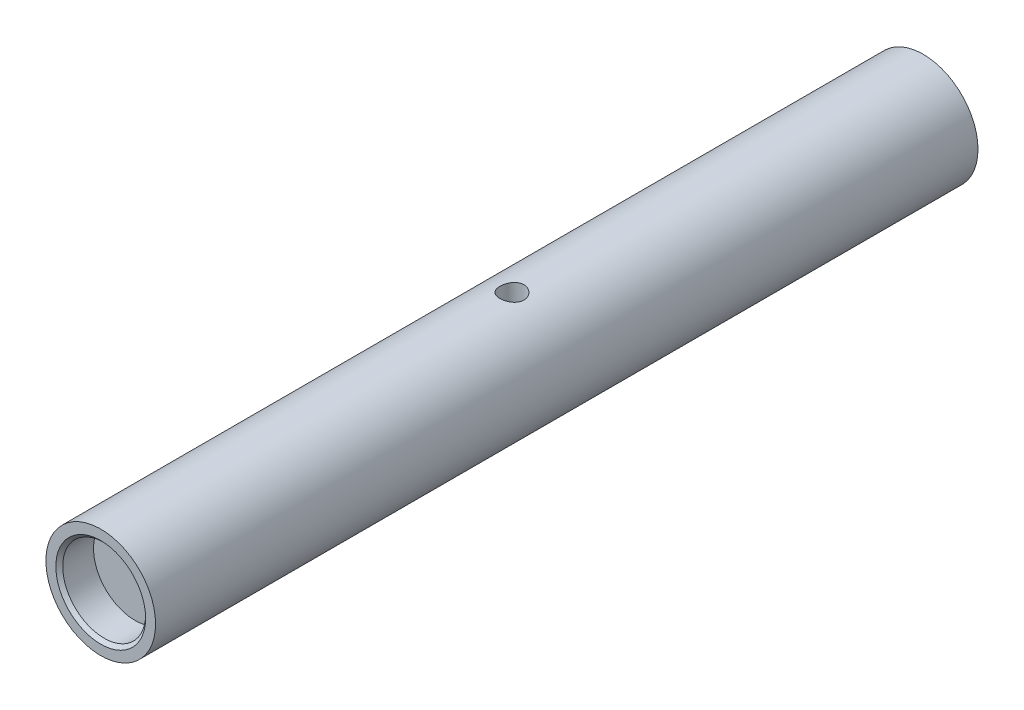
from build123d import *

# Parameters (mm, degrees)
SKETCH1_R               = 4
SKETCH1_R_2             = 3.025
BOSS_EXTRUDE1_DEPTH     = 60
SKETCH1_3_R             = 3.025
CUT_EXTRUDE1_DEPTH      = 2.5
CUT_EXTRUDE2_START      = 60
SKETCH1_4_R             = 3.025
CUT_EXTRUDE2_DEPTH      = 2.5
CHAMFER1_SIZE           = 0.25
SKETCH2_R               = 0.875
CUT_EXTRUDE3_DEPTH      = 61.266076693
CUT_EXTRUDE3_DEPTH_BACK = 61.266076693


with BuildPart() as part:
    # Sketch1 → Boss-Extrude1 (new body)
    with BuildSketch(Plane.XY):
        Circle(SKETCH1_R)
        Circle(SKETCH1_R_2, mode=Mode.SUBTRACT)
        Circle(SKETCH1_R_2)
    extrude(amount=BOSS_EXTRUDE1_DEPTH)

    # Sketch1_3 → Cut-Extrude1 (cut)
    with BuildSketch(Plane.XY):
        Circle(SKETCH1_3_R)
    extrude(amount=CUT_EXTRUDE1_DEPTH, mode=Mode.SUBTRACT)

    # Sketch1_4 → Cut-Extrude2 (cut)
    with BuildSketch(Plane.XY.offset(CUT_EXTRUDE2_START)):
        Circle(SKETCH1_4_R)
    extrude(amount=-CUT_EXTRUDE2_DEPTH, mode=Mode.SUBTRACT)

    # Chamfer1
    chamfer1_edges = [part.edges().sort_by_distance(p)[0] for p in [
        (-3.025, 0, 0),
        (-3.025, 0, 60),
    ]]
    chamfer(chamfer1_edges, length=CHAMFER1_SIZE)

    # Sketch2 → Cut-Extrude3 (cut, two sides)
    with BuildSketch(Plane(origin=(0, 0, 0), x_dir=(1, 0, 0), z_dir=(0, 1, 0))) as cut_extrude3_sk:
        with Locations(Location((0, -30, 0), (0, 0, 270))):
            Circle(SKETCH2_R)
    extrude(amount=CUT_EXTRUDE3_DEPTH, mode=Mode.SUBTRACT)
    extrude(cut_extrude3_sk.sketch, amount=-CUT_EXTRUDE3_DEPTH_BACK, mode=Mode.SUBTRACT)


solid = part.part
